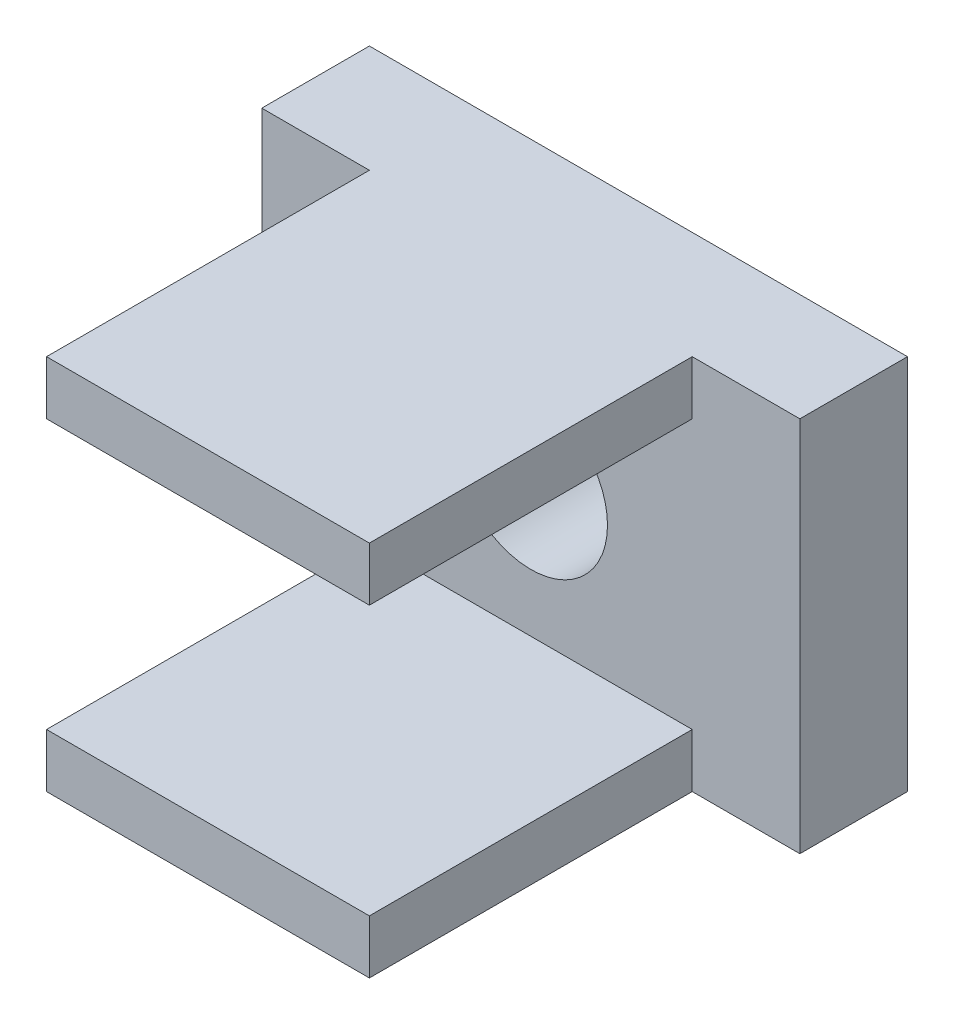
from build123d import *

# Parameters (mm, degrees)
SKETCH1_W           = 10
SKETCH1_H           = 7
BOSS_EXTRUDE1_DEPTH = 2
SKETCH2_R           = 1.425
CUT_EXTRUDE1_DEPTH  = 3
SKETCH3_W           = 6
SKETCH3_H           = 1
BOSS_EXTRUDE2_DEPTH = 6


with BuildPart() as part:
    # Sketch1 → Boss-Extrude1 (new body)
    with BuildSketch(Plane.XY):
        Rectangle(SKETCH1_W, SKETCH1_H)
    extrude(amount=BOSS_EXTRUDE1_DEPTH)

    # Sketch2 → Cut-Extrude1 (cut, through all)
    with BuildSketch(Plane.XY.offset(2)):
        Circle(SKETCH2_R)
    extrude(amount=-CUT_EXTRUDE1_DEPTH, mode=Mode.SUBTRACT)

    # Sketch3 → Boss-Extrude2 (add)
    with BuildSketch(Plane.XY.offset(2)):
        with Locations((0, 3)):
            Rectangle(SKETCH3_W, SKETCH3_H)
        with Locations((0, -3)):
            Rectangle(SKETCH3_W, SKETCH3_H)
    extrude(amount=BOSS_EXTRUDE2_DEPTH)


solid = part.part
